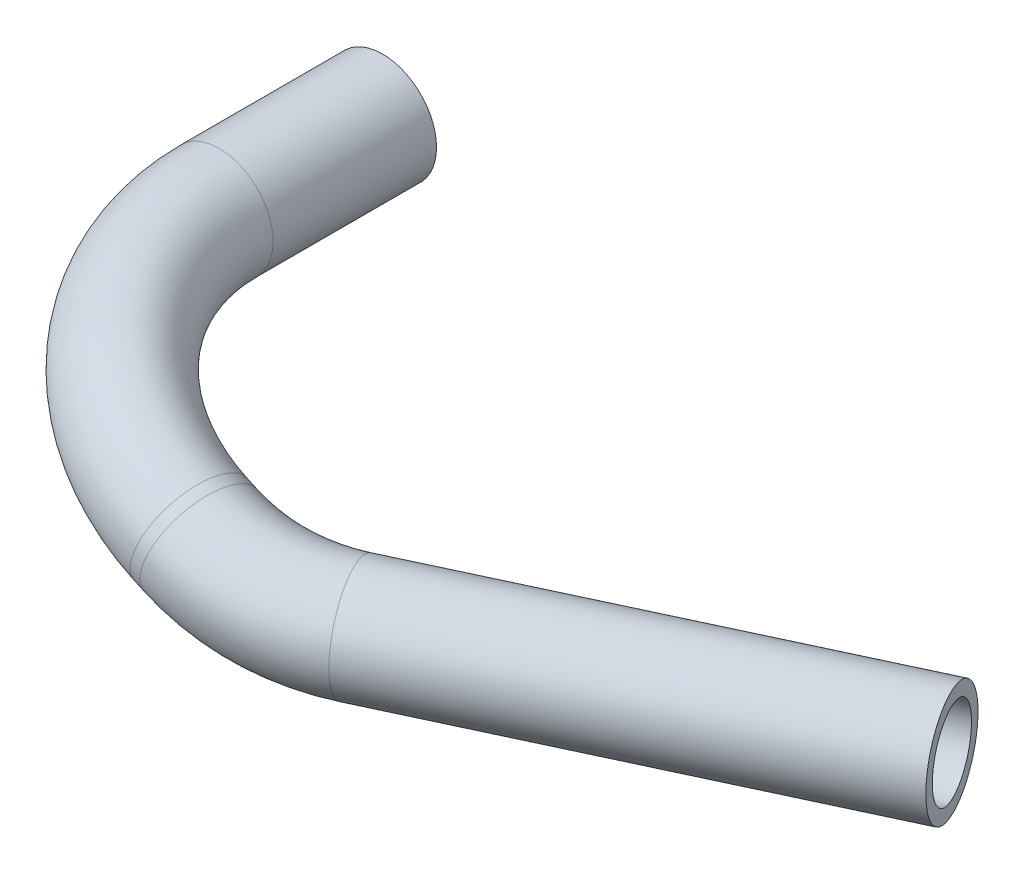
from build123d import *

# Parameters (mm, degrees)
SKETCH_1_R   = 4.765
SKETCH_1_R_2 = 3.58


with BuildPart() as part:
    # По траектории1: sweep along a curve in space
    with BuildLine() as sweep_1_path:
        Line((0, 0, 0), (0, 0, 14.460504946))
        ThreePointArc((17.378248064, -5.734487139, 34.388118956), (5.003679185, -1.651117755, 27.988232477), (0, 0, 14.460504946))
        Line((18.324445146, -6.046713952, 34.473121895), (17.378248064, -5.734487139, 34.388118956))
        ThreePointArc((29.914415781, -8, 32.362570038), (24.180183472, -7.500284638, 34.192857359), (18.324445146, -6.046713952, 34.473121895))
        Line((29.914415781, -8, 32.362570038), (65.938376067, -8, 15.576419335))
    # Эскиз1 → По траектории1 (sweep)
    with BuildSketch(Plane.XY):
        Circle(SKETCH_1_R)
        Circle(SKETCH_1_R_2, mode=Mode.SUBTRACT)
    sweep(path=sweep_1_path.line)


solid = part.part
